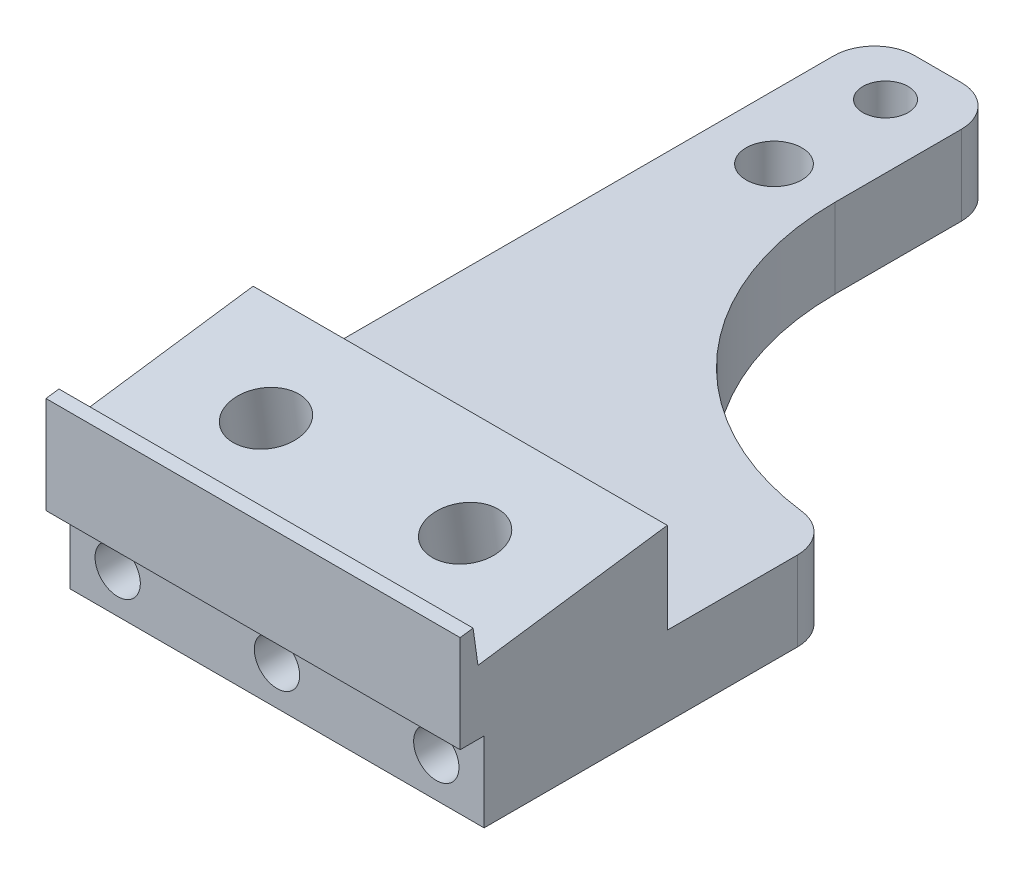
from build123d import *

# Parameters (mm, degrees)
SKETCH1_W                       = 26
SKETCH1_H                       = 51.5
EXTRUDE1_DEPTH                  = 5
SKETCH2_W                       = 18
SKETCH2_H                       = 28.3
EXTRUDE2_DEPTH                  = 5
FILLET1_R                       = 2.54
FILLET2_R                       = 18
EXTRUDE3_DEPTH                  = 26
SKETCH4_W                       = 26
SKETCH4_H                       = 5
EXTRUDE4_DEPTH                  = 1
F_4_40_TAPPED_HOLE1_D           = 2.2606
F_4_40_TAPPED_HOLE1_DEPTH       = 10.1346
F_4_40_TAPPED_HOLE1_CBORE_D     = 2.8448
F_4_40_TAPPED_HOLE1_CBORE_DEPTH = 8.2296
F_4_40_TAPPED_HOLE1_TIP         = 0.679152758
SKETCH6_R                       = 1.75
EXTRUDE5_DEPTH                  = 6.0000001
F_8_32_TAPPED_HOLE1_D           = 3.4544
F_8_32_TAPPED_HOLE1_DEPTH       = 10.7188
F_8_32_TAPPED_HOLE1_CBORE_D     = 4.1656
F_8_32_TAPPED_HOLE1_CBORE_DEPTH = 8.3312
F_8_32_TAPPED_HOLE1_TIP         = 1.037806461
F_4_40_TAPPED_HOLE2_D           = 2.2606
F_4_40_TAPPED_HOLE2_DEPTH       = 8.89
F_4_40_TAPPED_HOLE2_CBORE_D     = 2.8448
F_4_40_TAPPED_HOLE2_CBORE_DEPTH = 5.6896
F_4_40_TAPPED_HOLE2_TIP         = 0.679152758
SKETCH9_R                       = 0.5
EXTRUDE6_DEPTH                  = 2.032
BOSS_EXTRUDE2_DEPTH             = 26


with BuildPart() as part:
    # Sketch1 → Extrude1 (new body)
    with BuildSketch(Plane(origin=(0, 0, 0), x_dir=(1, 0, 0), z_dir=(0, 1, 0))):
        with Locations((-13, 25.75)):
            Rectangle(SKETCH1_W, SKETCH1_H)
    extrude(amount=EXTRUDE1_DEPTH)

    # Sketch2 → Extrude2 (cut)
    with BuildSketch(Plane(origin=(0, 5, 0), x_dir=(1, 0, 0), z_dir=(0, 1, 0))):
        with Locations((-9, 37.35)):
            Rectangle(SKETCH2_W, SKETCH2_H)
    extrude(amount=-EXTRUDE2_DEPTH, mode=Mode.SUBTRACT)

    # Fillet1
    fillet1_edges = [part.edges().sort_by_distance(p)[0] for p in [
        (0, 2.5, -23.2),
        (-18, 2.5, -51.5),
        (-26, 2.5, -51.5),
    ]]
    fillet(fillet1_edges, radius=FILLET1_R)

    # Fillet2
    fillet2_edges = [part.edges().sort_by_distance(p)[0] for p in [
        (-18, 2.5, -23.2),
    ]]
    fillet(fillet2_edges, radius=FILLET2_R)

    # Sketch3 → Extrude3 (add, through all)
    with BuildSketch(Plane(origin=(0, 0, 0), x_dir=(0, 0, -1), z_dir=(1, 0, 0))):
        Polygon((0, 5), (12.5, 5), (12.5, 10.7), (0.616783175, 9.029922788), (0.310602353, 11.20851254), (0, 11.164860226), align=None)
    extrude(amount=-EXTRUDE3_DEPTH)

    # Sketch4 → Extrude4 (cut)
    with BuildSketch(Plane.XY):
        with Locations((-13, 2.5)):
            Rectangle(SKETCH4_W, SKETCH4_H)
    extrude(amount=-EXTRUDE4_DEPTH, mode=Mode.SUBTRACT)

    # #4-40 Tapped Hole1
    with Locations(Plane(origin=(-22, 5, -48.2), x_dir=(0, 0, 1), z_dir=(0, 1, 0))):
        with Locations((0, 0)):
            CounterBoreHole(F_4_40_TAPPED_HOLE1_D / 2, F_4_40_TAPPED_HOLE1_CBORE_D / 2, F_4_40_TAPPED_HOLE1_CBORE_DEPTH, depth=F_4_40_TAPPED_HOLE1_DEPTH)
            with Locations((0, 0, -(F_4_40_TAPPED_HOLE1_DEPTH + F_4_40_TAPPED_HOLE1_TIP / 2))):  # 118° drill point
                Cone(0, F_4_40_TAPPED_HOLE1_D / 2, F_4_40_TAPPED_HOLE1_TIP, mode=Mode.SUBTRACT)

    # Sketch6 → Extrude5 (cut, through all)
    with BuildSketch(Plane(origin=(0, 5, 0), x_dir=(1, 0, 0), z_dir=(0, 1, 0))):
        with Locations(Location((-22, 41.2, 0), (0, 0, 270))):  # turned: the seam where the file's is
            Circle(SKETCH6_R)
    extrude(amount=-EXTRUDE5_DEPTH, mode=Mode.SUBTRACT)

    # #8-32 Tapped Hole1
    with Locations(Plane(origin=(-19.25, 9.864961394, -6.558391588), x_dir=(0, -0.139173101, 0.990268069), z_dir=(0, 0.990268069, 0.139173101))):
        with Locations((0, 0), (0, 12.5)):
            CounterBoreHole(F_8_32_TAPPED_HOLE1_D / 2, F_8_32_TAPPED_HOLE1_CBORE_D / 2, F_8_32_TAPPED_HOLE1_CBORE_DEPTH, depth=F_8_32_TAPPED_HOLE1_DEPTH)
            with Locations((0, 0, -(F_8_32_TAPPED_HOLE1_DEPTH + F_8_32_TAPPED_HOLE1_TIP / 2))):  # 118° drill point
                Cone(0, F_8_32_TAPPED_HOLE1_D / 2, F_8_32_TAPPED_HOLE1_TIP, mode=Mode.SUBTRACT)

    # #4-40 Tapped Hole2
    with Locations(Plane(origin=(-23, 2.5, -1), x_dir=(1, 0, 0), z_dir=(0, 0, 1))):
        with Locations((0, 0), (10, 0), (20, 0)):
            CounterBoreHole(F_4_40_TAPPED_HOLE2_D / 2, F_4_40_TAPPED_HOLE2_CBORE_D / 2, F_4_40_TAPPED_HOLE2_CBORE_DEPTH, depth=F_4_40_TAPPED_HOLE2_DEPTH)
            with Locations((0, 0, -(F_4_40_TAPPED_HOLE2_DEPTH + F_4_40_TAPPED_HOLE2_TIP / 2))):  # 118° drill point
                Cone(0, F_4_40_TAPPED_HOLE2_D / 2, F_4_40_TAPPED_HOLE2_TIP, mode=Mode.SUBTRACT)

    # Sketch9 → Extrude6 (cut)
    with BuildSketch(Plane.XZ):
        with Locations(Location((-23, -9.89, 0), (0, 0, 270))):  # turned: the seam where the file's is
            Circle(SKETCH9_R)
        with Locations(Location((-13, -9.89, 0), (0, 0, 270))):  # turned: the seam where the file's is
            Circle(SKETCH9_R)
        with Locations(Location((-3, -9.89, 0), (0, 0, 270))):  # turned: the seam where the file's is
            Circle(SKETCH9_R)
    extrude(amount=-EXTRUDE6_DEPTH, mode=Mode.SUBTRACT)

    # Sketch12 → Boss-Extrude2 (add)
    with BuildSketch(Plane(origin=(0, 0, 0), x_dir=(0, 0, -1), z_dir=(1, 0, 0))):
        Polygon((0, 11.164860226), (-0.5, 11.094589808), (-0.5, 5), (0, 5), align=None)
    extrude(amount=-BOSS_EXTRUDE2_DEPTH)


solid = part.part
